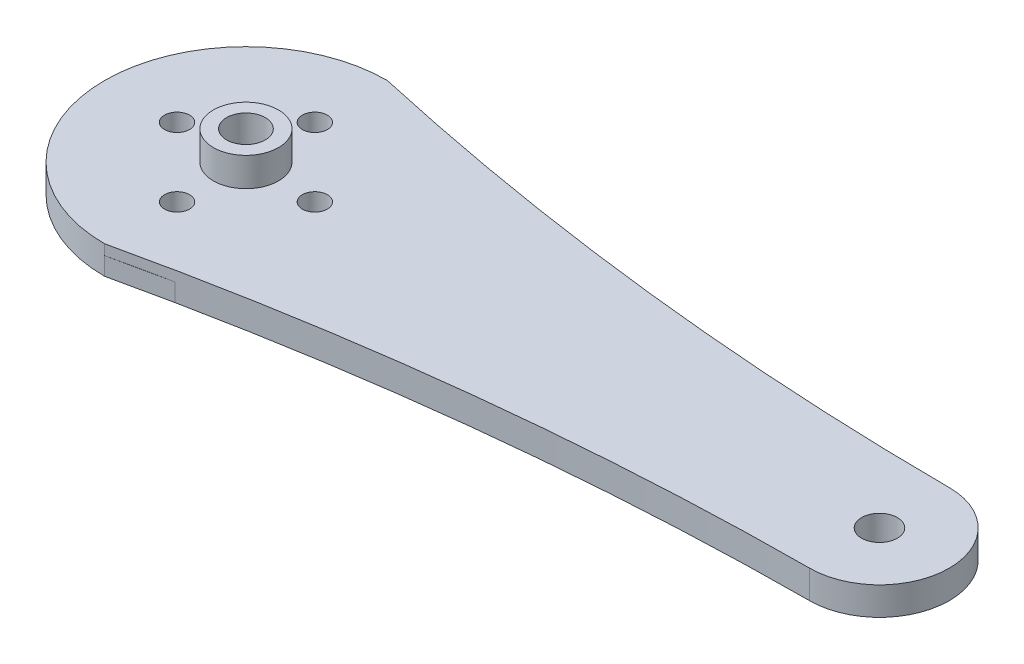
from build123d import *

# Parameters (mm, degrees)
SKETCH1_R                = 0.5
SKETCH1_R_2              = 1.375
BOSS_EXTRUDE1_DEPTH      = 2
SKETCH4_R                = 4.6270037
SKETCH4_R_2              = 2.6270037
BOSS_EXTRUDE3_DEPTH      = 2.5
SKETCH6_R                = 20.066
SKETCH6_R_2              = 3.75
BOSS_EXTRUDE6_DEPTH      = 2.54
SKETCH7_R                = 1.778
CUT_EXTRUDE4_DEPTH       = 2.54
CIRPATTERN1_COUNT        = 4
BOSS_EXTRU_1_DEPTH       = 2.2225
BOSS_EXTRU_1_DEPTH_BACK  = 2.54
ENL_V_MAT_EXTRU_1_REACH  = 6.5
ESQUISSE3_R              = 1.375
ESQUISSE3_R_2            = 1.778
BOSS_EXTRU_2_DEPTH       = 2.2225
ENL_V_MAT_EXTRU_2_REACH  = 6.763
ESQUISSE4_R              = 2.54
ESQUISSE8_W              = 140.858552016
ESQUISSE8_H              = 60.675995817
ENL_V_MAT_EXTRU_6_DEPTH  = 0.76
ESQUISSE9_R              = 4.625
BOSS_EXTRU_3_DEPTH       = 4.1
CUT_EXTRUDE3_DEPTH       = 3.3
ESQUISSE10_R             = 2.6270037
ESQUISSE10_R_2           = 1.375
ENL_V_MAT_EXTRU_8_DEPTH  = 0.8
ESQUISSE11_R             = 1.375
ENL_V_MAT_EXTRU_9_DEPTH  = 10
ESQUISSE12_R             = 2.75
ENL_V_MAT_EXTRU_10_DEPTH = 5.86


with BuildPart() as part:
    # Sketch1 → Boss-Extrude1 (new body)
    with BuildSketch(Plane(origin=(0, 0, 0), x_dir=(1, 0, 0), z_dir=(0, 1, 0))):
        with BuildLine():
            Line((-4, 4), (-2.467435953, 13.402193757))
            ThreePointArc((-2.467435953, 13.402193757), (0, 15.5), (2.467435953, 13.402193757))
            Line((2.467435953, 13.402193757), (4, 4))
            Line((4, 4), (12.448472752, 2.459445505))
            ThreePointArc((12.448472752, 2.459445505), (14.5, 0), (12.448472752, -2.459445505))
            Line((12.448472752, -2.459445505), (4, -4))
            Line((4, -4), (2.467435953, -13.402193757))
            ThreePointArc((2.467435953, -13.402193757), (0, -15.5), (-2.467435953, -13.402193757))
            Line((-2.467435953, -13.402193757), (-4, -4))
            Line((-4, -4), (-12.448472752, -2.459445505))
            ThreePointArc((-12.448472752, -2.459445505), (-14.5, 0), (-12.448472752, 2.459445505))
            Line((-12.448472752, 2.459445505), (-4, 4))
        make_face()
        with Locations((0, 12)):
            Circle(SKETCH1_R, mode=Mode.SUBTRACT)
        with Locations((0, 9.5)):
            Circle(SKETCH1_R, mode=Mode.SUBTRACT)
        with Locations((0, 7.5)):
            Circle(SKETCH1_R, mode=Mode.SUBTRACT)
        with Locations((12, 0)):
            Circle(SKETCH1_R, mode=Mode.SUBTRACT)
        with Locations((9.5, 0)):
            Circle(SKETCH1_R, mode=Mode.SUBTRACT)
        with Locations((7.5, 0)):
            Circle(SKETCH1_R, mode=Mode.SUBTRACT)
        with Locations((0, -12)):
            Circle(SKETCH1_R, mode=Mode.SUBTRACT)
        with Locations((0, -9.5)):
            Circle(SKETCH1_R, mode=Mode.SUBTRACT)
        with Locations((0, -7.5)):
            Circle(SKETCH1_R, mode=Mode.SUBTRACT)
        with Locations((-12, 0)):
            Circle(SKETCH1_R, mode=Mode.SUBTRACT)
        with Locations((-9.5, 0)):
            Circle(SKETCH1_R, mode=Mode.SUBTRACT)
        with Locations((-7.5, 0)):
            Circle(SKETCH1_R, mode=Mode.SUBTRACT)
        Circle(SKETCH1_R_2, mode=Mode.SUBTRACT)
    extrude(amount=BOSS_EXTRUDE1_DEPTH)

    # Sketch4 → Boss-Extrude3 (add)
    with BuildSketch(Plane.XZ):
        Circle(SKETCH4_R)
        Circle(SKETCH4_R_2, mode=Mode.SUBTRACT)
    extrude(amount=BOSS_EXTRUDE3_DEPTH)

    # Sketch6 → Boss-Extrude6 (add)
    with BuildSketch(Plane(origin=(0, 2, 0), x_dir=(1, 0, 0), z_dir=(0, 1, 0))):
        Circle(SKETCH6_R)
        Circle(SKETCH6_R_2, mode=Mode.SUBTRACT)
    extrude(amount=-BOSS_EXTRUDE6_DEPTH)

    # Sketch7 → Cut-Extrude4 (cut)
    with BuildSketch(Plane(origin=(0, 2, 0), x_dir=(1, 0, 0), z_dir=(0, 1, 0))):
        with Locations((0, 9.779)):
            Circle(SKETCH7_R)
    cut_extrude4 = extrude(amount=-CUT_EXTRUDE4_DEPTH, mode=Mode.SUBTRACT)

    # CirPattern1: Cut-Extrude4 ×4 about axis
    cirpattern1_axis = Axis((0, 0, 0), (0, 1, 0))
    for i in range(1, CIRPATTERN1_COUNT):
        add(cut_extrude4.rotate(cirpattern1_axis, i * 360 / CIRPATTERN1_COUNT), mode=Mode.SUBTRACT)

    # Esquisse1 → Boss.-Extru.1 (add, two sides)
    with BuildSketch(Plane(origin=(0, 2, 0), x_dir=(1, 0, 0), z_dir=(0, 1, 0))) as boss_extru_1_sk:
        with BuildLine():
            ThreePointArc((89.916, 9.906), (99.822, 0), (89.916, -9.906))
            ThreePointArc((89.916, -9.906), (44.681302905, -12.537230712), (0, -20.066))
            ThreePointArc((0, -20.066), (13.313004572, 0), (0, 20.066))
            ThreePointArc((0, 20.066), (44.681302905, 12.537230712), (89.916, 9.906))
        make_face()
    extrude(amount=BOSS_EXTRU_1_DEPTH)
    extrude(boss_extru_1_sk.sketch, amount=-BOSS_EXTRU_1_DEPTH_BACK)

    # Esquisse2 → Enlèv. mat.-Extru.1 (cut, up to next)
    with BuildSketch(Plane(origin=(0, 2, 0), x_dir=(1, 0, 0), z_dir=(0, 1, 0)), mode=Mode.PRIVATE) as enl_v_mat_extru_1_sk1:
        with BuildLine():
            Line((8.227715952, -18.301613214), (0, -20.066))
            ThreePointArc((0, -20.066), (4.207385486, -19.61994555), (8.227715952, -18.301613214))
        make_face()
    enl_v_mat_extru_1_tool1 = extrude(enl_v_mat_extru_1_sk1.sketch, amount=-ENL_V_MAT_EXTRU_1_REACH, mode=Mode.PRIVATE) & part.part
    add(enl_v_mat_extru_1_tool1.solids().sort_by_distance((4.151305, 2, 19.358429))[0], mode=Mode.SUBTRACT)
    # Esquisse2 → Enlèv. mat.-Extru.1 (cut, up to next)
    with BuildSketch(Plane(origin=(0, 2, 0), x_dir=(1, 0, 0), z_dir=(0, 1, 0)), mode=Mode.PRIVATE) as enl_v_mat_extru_1_sk2:
        with BuildLine():
            Line((8.227715952, 18.301613214), (0, 20.066))
            ThreePointArc((0, 20.066), (4.207385486, 19.61994555), (8.227715952, 18.301613214))
        make_face()
    enl_v_mat_extru_1_tool2 = extrude(enl_v_mat_extru_1_sk2.sketch, amount=-ENL_V_MAT_EXTRU_1_REACH, mode=Mode.PRIVATE) & part.part
    add(enl_v_mat_extru_1_tool2.solids().sort_by_distance((4.151305, 2, -19.358429))[0], mode=Mode.SUBTRACT)

    # Esquisse3 → Boss.-Extru.2 (add)
    with BuildSketch(Plane(origin=(0, 2, 0), x_dir=(1, 0, 0), z_dir=(0, 1, 0))):
        with BuildLine():
            ThreePointArc((0, -20.066), (13.313004572, 0), (0, 20.066))
            ThreePointArc((0, 20.066), (-20.066, 0), (0, -20.066))
        make_face()
        Circle(ESQUISSE3_R, mode=Mode.SUBTRACT)
        with Locations((0, 9.779)):
            Circle(ESQUISSE3_R_2, mode=Mode.SUBTRACT)
        with Locations((9.779, 0)):
            Circle(ESQUISSE3_R_2, mode=Mode.SUBTRACT)
        with Locations((0, -9.779)):
            Circle(ESQUISSE3_R_2, mode=Mode.SUBTRACT)
        with Locations((-9.779, 0)):
            Circle(ESQUISSE3_R_2, mode=Mode.SUBTRACT)
    extrude(amount=BOSS_EXTRU_2_DEPTH)

    # Esquisse4 → Enlèv. mat.-Extru.2 (cut, up to next)
    with BuildSketch(Plane(origin=(0, -0.54, 0), x_dir=(-1, 0, 0), z_dir=(0, -1, 0)), mode=Mode.PRIVATE) as enl_v_mat_extru_2_sk1:
        with Locations((-89.916, 0)):
            Circle(ESQUISSE4_R)
    enl_v_mat_extru_2_tool1 = extrude(enl_v_mat_extru_2_sk1.sketch, amount=-ENL_V_MAT_EXTRU_2_REACH, mode=Mode.PRIVATE) & part.part
    add(enl_v_mat_extru_2_tool1.solids().sort_by_distance((89.916, -0.54, 0))[0], mode=Mode.SUBTRACT)

    # Esquisse8 → Enlèv. mat.-Extru.6 (cut)
    with BuildSketch(Plane(origin=(0, 4.2225, 0), x_dir=(1, 0, 0), z_dir=(0, 1, 0))):
        with Locations((40.296950532, -0.55222117)):
            Rectangle(ESQUISSE8_W, ESQUISSE8_H)
    extrude(amount=-ENL_V_MAT_EXTRU_6_DEPTH, mode=Mode.SUBTRACT)

    # Esquisse9 → Boss.-Extru.3 (add)
    with BuildSketch(Plane(origin=(0, 3.4625, 0), x_dir=(1, 0, 0), z_dir=(0, 1, 0))):
        Circle(ESQUISSE9_R)
    extrude(amount=BOSS_EXTRU_3_DEPTH)

    # Sketch5 → Cut-Extrude3 (cut)
    with BuildSketch(Plane.XZ.offset(2.5)):
        with BuildLine():
            Line((0.282820055, 2.611735296), (0, 3.101594))
            Line((0, 3.101594), (-0.282820055, 2.611735296))
            ThreePointArc((-0.282820055, 2.611735296), (0, 2.6270037), (0.282820055, 2.611735296))
        make_face()
        with BuildLine():
            ThreePointArc((-1.076048447, 2.396511669), (-0.811788788, 2.498428987), (-0.538092735, 2.571304075))
            Line((-0.538092735, 2.571304075), (-0.958445256, 2.949791185))
            Line((-0.958445256, 2.949791185), (-1.076048447, 2.396511669))
        make_face()
        with BuildLine():
            Line((0.958445256, 2.949791185), (0.538092735, 2.571304075))
            ThreePointArc((0.538092735, 2.571304075), (0.811788788, 2.498428987), (1.076048447, 2.396511669))
            Line((1.076048447, 2.396511669), (0.958445256, 2.949791185))
        make_face()
        with BuildLine():
            ThreePointArc((-1.76394572, 1.946700782), (-1.544114033, 2.125290638), (-1.306333259, 2.279175696))
            Line((-1.306333259, 2.279175696), (-1.823071212, 2.509242256))
            Line((-1.823071212, 2.509242256), (-1.76394572, 1.946700782))
        make_face()
        with BuildLine():
            Line((1.823071212, 2.509242256), (1.306333259, 2.279175696))
            ThreePointArc((1.306333259, 2.279175696), (1.544114033, 2.125290638), (1.76394572, 1.946700782))
            Line((1.76394572, 1.946700782), (1.823071212, 2.509242256))
        make_face()
        with BuildLine():
            ThreePointArc((-2.279175696, 1.306333259), (-2.125290638, 1.544114033), (-1.946700782, 1.76394572))
            Line((-1.946700782, 1.76394572), (-2.509242256, 1.823071212))
            Line((-2.509242256, 1.823071212), (-2.279175696, 1.306333259))
        make_face()
        with BuildLine():
            Line((2.509242256, 1.823071212), (1.946700782, 1.76394572))
            ThreePointArc((1.946700782, 1.76394572), (2.125290638, 1.544114033), (2.279175696, 1.306333259))
            Line((2.279175696, 1.306333259), (2.509242256, 1.823071212))
        make_face()
        with BuildLine():
            ThreePointArc((-2.571304075, 0.538092735), (-2.498428987, 0.811788788), (-2.396511669, 1.076048447))
            Line((-2.396511669, 1.076048447), (-2.949791185, 0.958445256))
            Line((-2.949791185, 0.958445256), (-2.571304075, 0.538092735))
        make_face()
        with BuildLine():
            Line((2.949791185, 0.958445256), (2.396511669, 1.076048447))
            ThreePointArc((2.396511669, 1.076048447), (2.498428987, 0.811788788), (2.571304075, 0.538092735))
            Line((2.571304075, 0.538092735), (2.949791185, 0.958445256))
        make_face()
        with BuildLine():
            ThreePointArc((-2.611735296, -0.282820055), (-2.6270037, 0), (-2.611735296, 0.282820055))
            Line((-2.611735296, 0.282820055), (-3.101594, 0))
            Line((-3.101594, 0), (-2.611735296, -0.282820055))
        make_face()
        with BuildLine():
            Line((3.101594, 0), (2.611735296, 0.282820055))
            ThreePointArc((2.611735296, 0.282820055), (2.6270037, 0), (2.611735296, -0.282820055))
            Line((2.611735296, -0.282820055), (3.101594, 0))
        make_face()
        with BuildLine():
            ThreePointArc((-2.396511669, -1.076048447), (-2.498428987, -0.811788788), (-2.571304075, -0.538092735))
            Line((-2.571304075, -0.538092735), (-2.949791185, -0.958445256))
            Line((-2.949791185, -0.958445256), (-2.396511669, -1.076048447))
        make_face()
        with BuildLine():
            Line((2.949791185, -0.958445256), (2.571304075, -0.538092735))
            ThreePointArc((2.571304075, -0.538092735), (2.498428987, -0.811788788), (2.396511669, -1.076048447))
            Line((2.396511669, -1.076048447), (2.949791185, -0.958445256))
        make_face()
        with BuildLine():
            ThreePointArc((-1.946700782, -1.76394572), (-2.125290638, -1.544114033), (-2.279175696, -1.306333259))
            Line((-2.279175696, -1.306333259), (-2.509242256, -1.823071212))
            Line((-2.509242256, -1.823071212), (-1.946700782, -1.76394572))
        make_face()
        with BuildLine():
            Line((2.509242256, -1.823071212), (2.279175696, -1.306333259))
            ThreePointArc((2.279175696, -1.306333259), (2.125290638, -1.544114033), (1.946700782, -1.76394572))
            Line((1.946700782, -1.76394572), (2.509242256, -1.823071212))
        make_face()
        with BuildLine():
            ThreePointArc((-1.306333259, -2.279175696), (-1.544114033, -2.125290638), (-1.76394572, -1.946700782))
            Line((-1.76394572, -1.946700782), (-1.823071212, -2.509242256))
            Line((-1.823071212, -2.509242256), (-1.306333259, -2.279175696))
        make_face()
        with BuildLine():
            Line((1.823071212, -2.509242256), (1.76394572, -1.946700782))
            ThreePointArc((1.76394572, -1.946700782), (1.544114033, -2.125290638), (1.306333259, -2.279175696))
            Line((1.306333259, -2.279175696), (1.823071212, -2.509242256))
        make_face()
        with BuildLine():
            ThreePointArc((-0.538092735, -2.571304075), (-0.811788788, -2.498428987), (-1.076048447, -2.396511669))
            Line((-1.076048447, -2.396511669), (-0.958445256, -2.949791185))
            Line((-0.958445256, -2.949791185), (-0.538092735, -2.571304075))
        make_face()
        with BuildLine():
            Line((0.958445256, -2.949791185), (1.076048447, -2.396511669))
            ThreePointArc((1.076048447, -2.396511669), (0.811788788, -2.498428987), (0.538092735, -2.571304075))
            Line((0.538092735, -2.571304075), (0.958445256, -2.949791185))
        make_face()
        with BuildLine():
            ThreePointArc((0.282820055, -2.611735296), (0, -2.6270037), (-0.282820055, -2.611735296))
            Line((-0.282820055, -2.611735296), (0, -3.101594))
            Line((0, -3.101594), (0.282820055, -2.611735296))
        make_face()
    extrude(amount=-CUT_EXTRUDE3_DEPTH, mode=Mode.SUBTRACT)

    # Esquisse10 → Enlèv. mat.-Extru.8 (cut)
    with BuildSketch(Plane(origin=(0, 0, 0), x_dir=(-1, 0, 0), z_dir=(0, -1, 0))):
        Circle(ESQUISSE10_R)
        Circle(ESQUISSE10_R_2, mode=Mode.SUBTRACT)
    extrude(amount=-ENL_V_MAT_EXTRU_8_DEPTH, mode=Mode.SUBTRACT)

    # Esquisse11 → Enlèv. mat.-Extru.9 (cut)
    with BuildSketch(Plane(origin=(0, 3.4625, 0), x_dir=(-1, 0, 0), z_dir=(0, -1, 0))):
        Circle(ESQUISSE11_R)
    extrude(amount=-ENL_V_MAT_EXTRU_9_DEPTH, mode=Mode.SUBTRACT)

    # Esquisse12 → Enlèv. mat.-Extru.10 (cut)
    with BuildSketch(Plane(origin=(0, 7.5625, 0), x_dir=(1, 0, 0), z_dir=(0, 1, 0))):
        Circle(ESQUISSE12_R)
    extrude(amount=-ENL_V_MAT_EXTRU_10_DEPTH, mode=Mode.SUBTRACT)


solid = part.part
